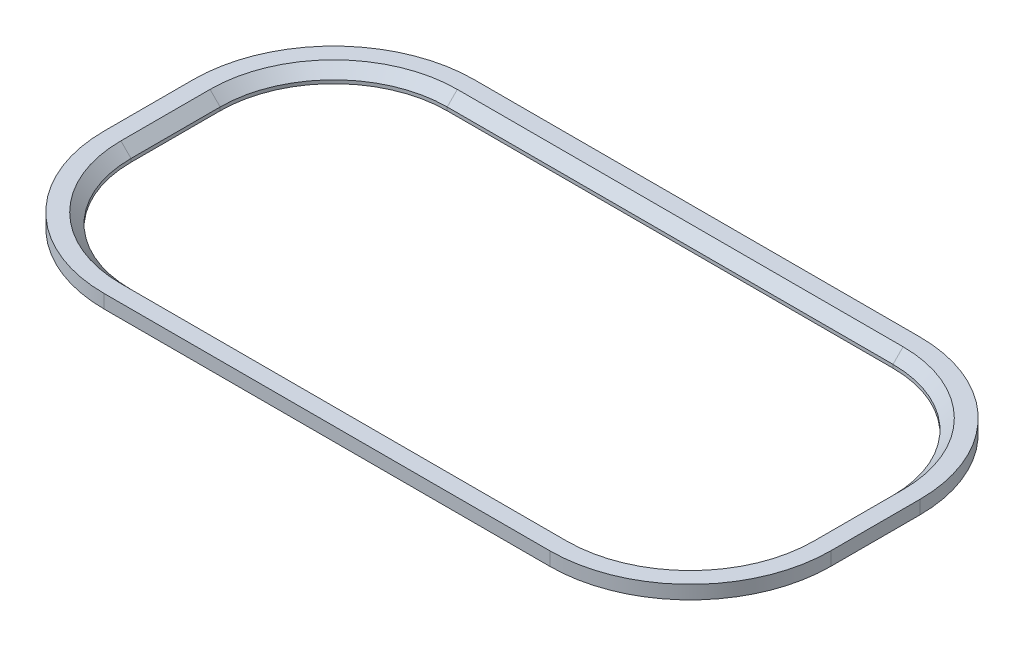
from build123d import *

# Parameters (mm, degrees)
BOSS_EXTRUDE1_DEPTH = 2.54
CHAMFER1_SIZE       = 1.905


with BuildPart() as part:
    # Sketch1 → Boss-Extrude1 (new body)
    with BuildSketch(Plane(origin=(0, 0, 0), x_dir=(1, 0, 0), z_dir=(0, 1, 0))):
        with BuildLine():
            Line((0, -5.08), (83.82, -5.08))
            ThreePointArc((83.82, -5.08), (102.505005172, 2.659582555), (110.244587728, 21.344587728))
            Line((110.244587728, 21.344587728), (110.244587728, 38.108587728))
            ThreePointArc((110.244587728, 38.108587728), (102.505005172, 56.7935929), (83.82, 64.533175456))
            Line((83.82, 64.533175456), (0, 64.533175456))
            ThreePointArc((0, 64.533175456), (-18.685005172, 56.7935929), (-26.424587728, 38.108587728))
            Line((-26.424587728, 38.108587728), (-26.424587728, 21.344587728))
            ThreePointArc((-26.424587728, 21.344587728), (-18.685005172, 2.659582555), (0, -5.08))
        make_face()
        with BuildLine():
            Line((0, 0), (83.82, 0))
            ThreePointArc((83.82, 0), (98.912902724, 6.251685004), (105.164587728, 21.344587728))
            Line((105.164587728, 21.344587728), (105.164587728, 38.108587728))
            ThreePointArc((105.164587728, 38.108587728), (98.912902724, 53.201490452), (83.82, 59.453175456))
            Line((83.82, 59.453175456), (0, 59.453175456))
            ThreePointArc((0, 59.453175456), (-15.092902724, 53.201490452), (-21.344587728, 38.108587728))
            Line((-21.344587728, 38.108587728), (-21.344587728, 21.344587728))
            ThreePointArc((-21.344587728, 21.344587728), (-15.092902724, 6.251685004), (0, 0))
        make_face(mode=Mode.SUBTRACT)
    extrude(amount=BOSS_EXTRUDE1_DEPTH)

    # Chamfer1
    chamfer1_edges = [part.edges().sort_by_distance(p)[0] for p in [
        (-15.092902724, 2.54, -6.251685004),
        (41.91, 2.54, 0),
        (98.912902724, 2.54, -6.251685004),
        (105.164587728, 2.54, -29.726587728),
        (98.912902724, 2.54, -53.201490452),
        (41.91, 2.54, -59.453175456),
        (-15.092902724, 2.54, -53.201490452),
        (-21.344587728, 2.54, -29.726587728),
    ]]
    chamfer(chamfer1_edges, length=CHAMFER1_SIZE)


solid = part.part
